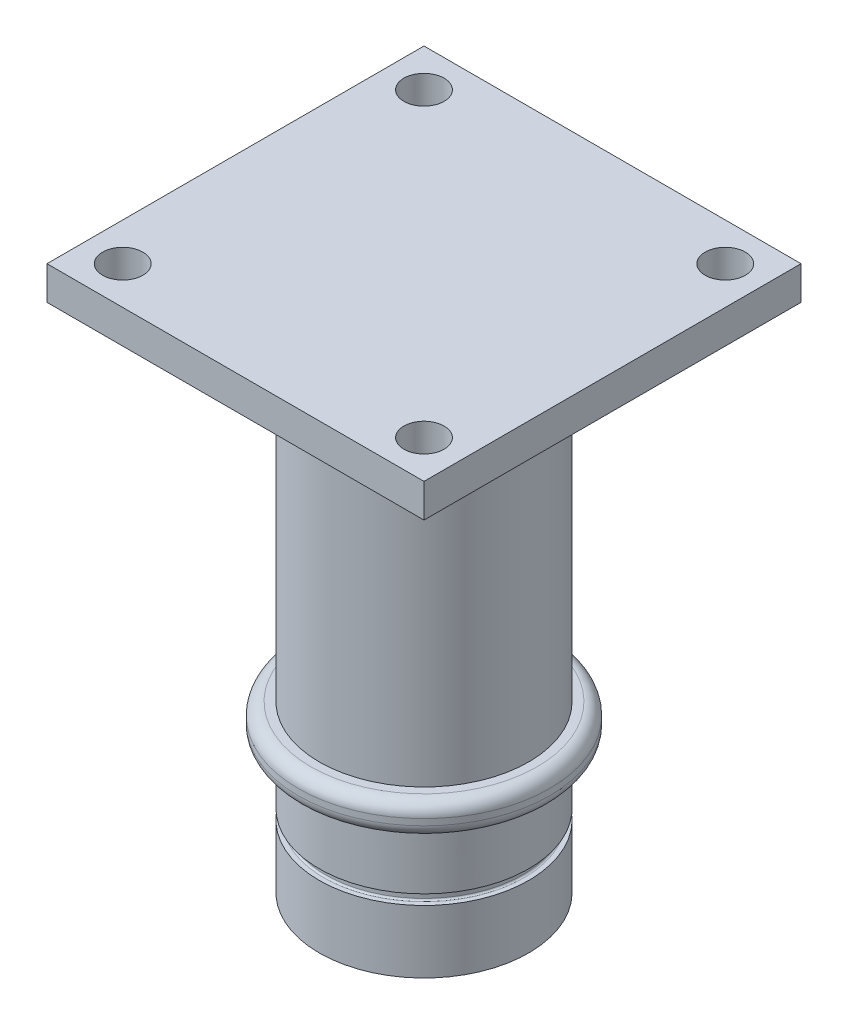
from build123d import *

# Parameters (mm, degrees)
SKETCH1_R            = 12.5
BOSS_EXTRUDE1_DEPTH  = 16
BOSS_EXTRUDE2_DEPTH  = 0.32
SKETCH4_R            = 15
BOSS_EXTRUDE3_DEPTH  = 45
SKETCH5_W            = 45
SKETCH5_H            = 45
BOSS_EXTRUDE4_DEPTH  = 4
FILLET1_R            = 1.5
M4_CLEARANCE_HOLE1_D = 4.8
SKETCH26_W           = 3.470226455
SKETCH26_H           = 40.019428233
FILLET3_R            = 1.5


with BuildPart() as part:
    # Sketch1 → Boss-Extrude1 (new body)
    with BuildSketch(Plane(origin=(0, 0, 0), x_dir=(1, 0, 0), z_dir=(0, 1, 0))):
        Circle(SKETCH1_R)
    extrude(amount=BOSS_EXTRUDE1_DEPTH)

    # Sketch3 → Boss-Extrude2 (add)
    with BuildSketch(Plane(origin=(0, 0, 0), x_dir=(-1, 0, 0), z_dir=(0, -1, 0))):
        with BuildLine():
            Line((-6.291079157, 1.543222531), (-6.919284285, 1.543222531))
            add(Edge.make_bspline(
                [(-6.919284285, 1.543222531), (-6.916571164, 1.590742925), (-6.911269887, 1.683594923), (-6.890182748, 1.818465423), (-6.861926706, 1.945903214), (-6.824215266, 2.065462506), (-6.776828375, 2.177099854), (-6.720985418, 2.281195836), (-6.655259736, 2.377202384), (-6.581050187, 2.464656501), (-6.499616645, 2.543112396), (-6.41264975, 2.612676322), (-6.318819227, 2.670078723), (-6.219839436, 2.717315584), (-6.11572723, 2.755055642), (-6.005497546, 2.780287924), (-5.890104812, 2.797375473), (-5.81110914, 2.798870702), (-5.770846785, 2.799632787)],
                knots=[0, 0, 0, 0, 0.000142716, 0.000278858, 0.000408976, 0.000534035, 0.000654361, 0.000772316, 0.000887831, 0.001002741, 0.001115793, 0.001226606, 0.001336154, 0.001444972, 0.001555191, 0.0016676, 0.00178371, 0.001904402, 0.001904402, 0.001904402, 0.001904402], degree=3))
            add(Edge.make_bspline(
                [(-5.770846785, 2.799632787), (-5.721425316, 2.798090707), (-5.624943026, 2.795080205), (-5.484746605, 2.769399626), (-5.353818476, 2.726444888), (-5.232253813, 2.666425791), (-5.121087516, 2.59017782), (-5.020338019, 2.499264594), (-4.933052148, 2.391778705), (-4.858676485, 2.272192465), (-4.796879198, 2.145567468), (-4.753574234, 2.014631969), (-4.725110347, 1.882860468), (-4.722074497, 1.794132208), (-4.720566337, 1.75005346)],
                knots=[0, 0, 0, 0, 0.000148176, 0.000289274, 0.00042585, 0.000560365, 0.000694549, 0.000829057, 0.000966049, 0.001108444, 0.001250813, 0.001387611, 0.0015214, 0.001653479, 0.001653479, 0.001653479, 0.001653479], degree=3))
            add(Edge.make_bspline(
                [(-4.720566337, 1.75005346), (-4.721153535, 1.723391518), (-4.722335419, 1.669727615), (-4.73055322, 1.588520958), (-4.742881545, 1.505802484), (-4.761469655, 1.421643116), (-4.784650551, 1.336019263), (-4.812772329, 1.248674681), (-4.846487301, 1.160104584), (-4.885232833, 1.069312129), (-4.93145635, 0.976002549), (-4.985277211, 0.878777096), (-5.048123942, 0.777722019), (-5.119237436, 0.672266726), (-5.198963072, 0.562577537), (-5.287690046, 0.448984871), (-5.384396431, 0.331088462), (-5.453031673, 0.252281329), (-5.488294702, 0.211792242)],
                knots=[0, 0, 0, 0, 7.9977e-05, 0.000160974, 0.000244663, 0.00033075, 0.000419361, 0.000510712, 0.000605902, 0.000703579, 0.00080674, 0.00091815, 0.001036838, 0.001163625, 0.001299659, 0.001443551, 0.001595983, 0.001757052, 0.001757052, 0.001757052, 0.001757052], degree=3))
            Line((-5.488294702, 0.211792242), (-5.853579157, -0.206777469))
            Line((-5.853579157, -0.206777469), (-4.675694542, -0.206777469))
            Line((-4.675694542, -0.206777469), (-4.675694542, -0.790110802))
            Line((-4.675694542, -0.790110802), (-7.009027875, -0.790110802))
            Line((-7.009027875, -0.790110802), (-7.009027875, -0.471801508))
            Line((-7.009027875, -0.471801508), (-5.972769862, 0.631063076))
            add(Edge.make_bspline(
                [(-5.972769862, 0.631063076), (-5.94276753, 0.663233978), (-5.884661909, 0.725539476), (-5.801983599, 0.817041727), (-5.727167032, 0.90387518), (-5.66176359, 0.986964434), (-5.602340985, 1.063614414), (-5.551548866, 1.136135444), (-5.508922525, 1.203871909), (-5.462645586, 1.285550256), (-5.418697706, 1.382966219), (-5.378372866, 1.495193403), (-5.353792086, 1.602456744), (-5.350399161, 1.672351843), (-5.348771465, 1.705882787)],
                knots=[0, 0, 0, 0, 0.000131967, 0.000255582, 0.000369957, 0.000475731, 0.00057277, 0.00066088, 0.000741219, 0.000812792, 0.000942363, 0.001061215, 0.001170268, 0.001270825, 0.001270825, 0.001270825, 0.001270825], degree=3))
            add(Edge.make_bspline(
                [(-5.348771465, 1.705882787), (-5.349988454, 1.738321389), (-5.352346565, 1.80117638), (-5.378260299, 1.89058727), (-5.418406753, 1.971539704), (-5.474978777, 2.041614731), (-5.543505217, 2.099200028), (-5.622693954, 2.142030354), (-5.711899369, 2.166743256), (-5.774434064, 2.169836428), (-5.806603997, 2.171427659)],
                knots=[0, 0, 0, 0, 9.7062e-05, 0.000188073, 0.000276808, 0.000366596, 0.000456186, 0.000543702, 0.000634713, 0.000731135, 0.000731135, 0.000731135, 0.000731135], degree=3))
            add(Edge.make_bspline(
                [(-5.806603997, 2.171427659), (-5.823223394, 2.170839839), (-5.855941346, 2.169682622), (-5.904034178, 2.161979337), (-5.949797963, 2.148403101), (-5.993742077, 2.130212856), (-6.035397537, 2.106101555), (-6.074659275, 2.076380536), (-6.111940963, 2.041805077), (-6.147071611, 2.00248329), (-6.179045088, 1.958600165), (-6.207443813, 1.910556483), (-6.230924831, 1.858382067), (-6.251598373, 1.8027657), (-6.267542797, 1.743110015), (-6.279152316, 1.679772045), (-6.287978258, 1.612854834), (-6.290026721, 1.566855543), (-6.291079157, 1.543222531)],
                knots=[0, 0, 0, 0, 4.9859e-05, 9.8155e-05, 0.000145635, 0.000192772, 0.000240515, 0.000289593, 0.000340201, 0.000392836, 0.000447528, 0.000502841, 0.000559939, 0.000618941, 0.00068068, 0.000744897, 0.000812032, 0.000882971, 0.000882971, 0.000882971, 0.000882971], degree=3))
        make_face()
        with BuildLine():
            Line((-3.621908484, 2.709889198), (-2.028258644, 2.709889198))
            Line((-2.028258644, 2.709889198), (-2.028258644, 2.126555864))
            Line((-2.028258644, 2.126555864), (-3.12411201, 2.126555864))
            Line((-3.12411201, 2.126555864), (-3.26083076, 1.46469689))
            add(Edge.make_bspline(
                [(-3.26083076, 1.46469689), (-3.242200873, 1.469885549), (-3.205458909, 1.480118649), (-3.150107094, 1.490381155), (-3.096463471, 1.497032985), (-3.061262853, 1.49792025), (-3.044184125, 1.498350736)],
                knots=[0, 0, 0, 0, 5.799e-05, 0.000114368, 0.000168722, 0.000219947, 0.000219947, 0.000219947, 0.000219947], degree=3))
            add(Edge.make_bspline(
                [(-3.044184125, 1.498350736), (-3.006967787, 1.497497945), (-2.933606187, 1.495816907), (-2.826287475, 1.479858368), (-2.723523468, 1.454724152), (-2.625628637, 1.418877575), (-2.53269861, 1.372222329), (-2.444620738, 1.31578256), (-2.361286921, 1.249459139), (-2.284177518, 1.173210542), (-2.213326177, 1.089487857), (-2.151724977, 0.998932913), (-2.099113708, 0.902836937), (-2.057268524, 0.800602599), (-2.024240737, 0.692871998), (-2.000374121, 0.579576097), (-1.986260599, 0.460580625), (-1.984357477, 0.379398522), (-1.98338685, 0.337994165)],
                knots=[0, 0, 0, 0, 0.000111586, 0.000219961, 0.00032471, 0.000428519, 0.000531991, 0.000636043, 0.000741817, 0.000850891, 0.00096086, 0.001070345, 0.001178899, 0.001288921, 0.00140114, 0.00151651, 0.001635827, 0.001760022, 0.001760022, 0.001760022, 0.001760022], degree=3))
            add(Edge.make_bspline(
                [(-1.98338685, 0.337994165), (-1.984572971, 0.296119774), (-1.986913536, 0.21348936), (-2.002183578, 0.091993422), (-2.029135476, -0.024372259), (-2.066156605, -0.13591919), (-2.114929572, -0.241827528), (-2.173585741, -0.343194406), (-2.243116827, -0.439267408), (-2.322840495, -0.52906167), (-2.409510579, -0.611135349), (-2.50179376, -0.683335722), (-2.599041719, -0.744091751), (-2.701256805, -0.793192894), (-2.807852575, -0.832040844), (-2.918861384, -0.860320297), (-3.03482272, -0.876536993), (-3.1135454, -0.878736441), (-3.153559125, -0.879854392)],
                knots=[0, 0, 0, 0, 0.000125626, 0.000247897, 0.00036661, 0.000483454, 0.000599853, 0.000715778, 0.000834286, 0.000954987, 0.001075509, 0.001191914, 0.001305919, 0.001418808, 0.001531482, 0.001645754, 0.001761863, 0.001881886, 0.001881886, 0.001881886, 0.001881886], degree=3))
            add(Edge.make_bspline(
                [(-3.153559125, -0.879854392), (-3.189342209, -0.878939838), (-3.259913938, -0.877136147), (-3.363862997, -0.86604971), (-3.464081433, -0.846448784), (-3.560037195, -0.81808117), (-3.6527399, -0.783167113), (-3.741117877, -0.739500487), (-3.825656778, -0.687912762), (-3.906116545, -0.629345417), (-3.98118982, -0.563371574), (-4.049708751, -0.491151836), (-4.11208816, -0.413596497), (-4.166993225, -0.329748761), (-4.214251835, -0.239732507), (-4.256161735, -0.144608598), (-4.290465408, -0.043383637), (-4.307873534, 0.02679113), (-4.316720183, 0.0624533)],
                knots=[0, 0, 0, 0, 0.000107354, 0.000211725, 0.000313201, 0.000413265, 0.000511575, 0.000610032, 0.000708511, 0.000808359, 0.000908217, 0.001007897, 0.001106663, 0.001206422, 0.001308044, 0.00141134, 0.001517986, 0.001628185, 0.001628185, 0.001628185, 0.001628185], degree=3))
            Line((-4.316720183, 0.0624533), (-3.598771465, 0.0624533))
            add(Edge.make_bspline(
                [(-3.598771465, 0.0624533), (-3.585647345, 0.037740869), (-3.560142116, -0.010284921), (-3.511625531, -0.074046374), (-3.457314294, -0.128419402), (-3.397698323, -0.17393524), (-3.332391343, -0.208034932), (-3.264054489, -0.233894561), (-3.191829275, -0.248837882), (-3.142640716, -0.250705946), (-3.117801914, -0.251649264)],
                knots=[0, 0, 0, 0, 8.3833e-05, 0.00016292, 0.000239268, 0.000313868, 0.00038695, 0.000459491, 0.000532506, 0.000606986, 0.000606986, 0.000606986, 0.000606986], degree=3))
            add(Edge.make_bspline(
                [(-3.117801914, -0.251649264), (-3.100489602, -0.250997895), (-3.066427337, -0.249716315), (-3.016241976, -0.242936434), (-2.968337843, -0.230095494), (-2.922358785, -0.212313777), (-2.878181288, -0.190137967), (-2.836438652, -0.162142453), (-2.796404632, -0.129918577), (-2.758688707, -0.092941571), (-2.72452895, -0.051720811), (-2.694574579, -0.007426293), (-2.667791241, 0.038957747), (-2.647952414, 0.089268698), (-2.631706091, 0.142004258), (-2.619741642, 0.197562227), (-2.612591534, 0.256007492), (-2.611929626, 0.295906436), (-2.611591978, 0.31625939)],
                knots=[0, 0, 0, 0, 5.1959e-05, 0.00010223, 0.000151548, 0.000200376, 0.000249918, 0.000299504, 0.000350859, 0.000403908, 0.00045768, 0.000511159, 0.000564208, 0.00061798, 0.000672982, 0.000729638, 0.000788252, 0.000849286, 0.000849286, 0.000849286, 0.000849286], degree=3))
            add(Edge.make_bspline(
                [(-2.611591978, 0.31625939), (-2.611983857, 0.336139906), (-2.61274666, 0.374837812), (-2.619056719, 0.4316602), (-2.630345293, 0.485574363), (-2.645726071, 0.536993243), (-2.665415304, 0.5856046), (-2.689476862, 0.631697791), (-2.71801354, 0.675039833), (-2.751178544, 0.714748324), (-2.786545363, 0.751170082), (-2.824540692, 0.783024261), (-2.864822211, 0.809461017), (-2.906138223, 0.832541075), (-2.950137915, 0.849338238), (-2.995831909, 0.860905825), (-3.043172153, 0.869393654), (-3.075461906, 0.869892345), (-3.091860407, 0.870145608)],
                knots=[0, 0, 0, 0, 5.9632e-05, 0.000116076, 0.000171216, 0.000224671, 0.00027688, 0.000328311, 0.000380426, 0.000432223, 0.00048329, 0.000532573, 0.000580604, 0.000627663, 0.000674276, 0.000721381, 0.000768985, 0.000818109, 0.000818109, 0.000818109, 0.000818109], degree=3))
            add(Edge.make_bspline(
                [(-3.091860407, 0.870145608), (-3.109672991, 0.869469719), (-3.14537323, 0.868115093), (-3.19841485, 0.857092866), (-3.250816936, 0.839254766), (-3.302870896, 0.814644281), (-3.354060006, 0.782436922), (-3.405735171, 0.744661381), (-3.456166712, 0.698572909), (-3.488232489, 0.66424611), (-3.504821144, 0.646487755)],
                knots=[0, 0, 0, 0, 5.34e-05, 0.000107026, 0.00016179, 0.000219183, 0.000279308, 0.000342972, 0.00041098, 0.000483874, 0.000483874, 0.000483874, 0.000483874], degree=3))
            Line((-3.504821144, 0.646487755), (-4.033466978, 0.767781826))
            Line((-4.033466978, 0.767781826), (-3.621908484, 2.709889198))
        make_face()
        with BuildLine():
            Line((-1.400053516, 1.767581505), (-0.771848388, 1.767581505))
            Line((-0.771848388, 1.767581505), (-0.771848388, 1.461892403))
            add(Edge.make_bspline(
                [(-0.771848388, 1.461892403), (-0.743906143, 1.490094158), (-0.688890159, 1.545621095), (-0.597717912, 1.617005965), (-0.502616027, 1.678048848), (-0.402432018, 1.727466904), (-0.297410934, 1.765201159), (-0.188050517, 1.792852264), (-0.073789049, 1.80916555), (0.004007568, 1.811345235), (0.043556259, 1.8124533)],
                knots=[0, 0, 0, 0, 0.000119001, 0.000234303, 0.000346528, 0.000457527, 0.000568643, 0.000680705, 0.000795425, 0.000914048, 0.000914048, 0.000914048, 0.000914048], degree=3))
            add(Edge.make_bspline(
                [(0.043556259, 1.8124533), (0.083157169, 1.811207675), (0.161110278, 1.808755703), (0.274843322, 1.786317857), (0.382587209, 1.74986394), (0.483156505, 1.69790336), (0.577278064, 1.633734745), (0.66078224, 1.554042942), (0.735946033, 1.462000309), (0.776011228, 1.392415088), (0.796561067, 1.356724133)],
                knots=[0, 0, 0, 0, 0.000118697, 0.000233651, 0.000346285, 0.000458854, 0.000572239, 0.000686814, 0.000803976, 0.00092735, 0.00092735, 0.00092735, 0.00092735], degree=3))
            add(Edge.make_bspline(
                [(0.796561067, 1.356724133), (0.823031915, 1.392512181), (0.874986762, 1.462754076), (0.967081459, 1.554462834), (1.066663304, 1.633743055), (1.175658975, 1.698377098), (1.291173926, 1.749686581), (1.412702677, 1.786182411), (1.539143407, 1.808718203), (1.625193264, 1.811197924), (1.66875658, 1.8124533)],
                knots=[0, 0, 0, 0, 0.000133377, 0.000261782, 0.000388582, 0.000514355, 0.000640857, 0.00076684, 0.000894209, 0.001024806, 0.001024806, 0.001024806, 0.001024806], degree=3))
            add(Edge.make_bspline(
                [(1.66875658, 1.8124533), (1.713752313, 1.811149786), (1.801377319, 1.808611314), (1.928358537, 1.783637189), (2.047291813, 1.745048419), (2.155548756, 1.688892314), (2.253438125, 1.622373184), (2.336851675, 1.543778056), (2.406077301, 1.45584945), (2.45115206, 1.373745586), (2.480291681, 1.301156369), (2.497886443, 1.237990149), (2.51434299, 1.167457075), (2.526165371, 1.088609083), (2.537201043, 1.002187284), (2.543607684, 0.907617117), (2.547962345, 0.805217165), (2.548424865, 0.734367196), (2.548664433, 0.697669646)],
                knots=[0, 0, 0, 0, 0.000134836, 0.000262581, 0.000386741, 0.000508716, 0.000627156, 0.000740739, 0.000851119, 0.000961576, 0.001020424, 0.001085432, 0.001158059, 0.001237592, 0.001324469, 0.00141938, 0.00152183, 0.001631915, 0.001631915, 0.001631915, 0.001631915], degree=3))
            Line((2.548664433, 0.697669646), (2.548664433, -0.790110802))
            Line((2.548664433, -0.790110802), (1.920459304, -0.790110802))
            Line((1.920459304, -0.790110802), (1.920459304, 0.494344326))
            add(Edge.make_bspline(
                [(1.920459304, 0.494344326), (1.919936443, 0.528701113), (1.918932857, 0.594645861), (1.914666226, 0.689231012), (1.905115682, 0.775011582), (1.89392122, 0.852462715), (1.87790173, 0.921173756), (1.85836887, 0.981310341), (1.835710871, 1.032959035), (1.808352021, 1.076114456), (1.777710076, 1.112458136), (1.743625333, 1.143611868), (1.706453177, 1.170192166), (1.665856587, 1.192848092), (1.620772039, 1.208170744), (1.572721513, 1.220193443), (1.521329002, 1.228380988), (1.485796231, 1.228869105), (1.467534625, 1.229119967)],
                knots=[0, 0, 0, 0, 0.000103086, 0.000197865, 0.000283886, 0.000361925, 0.000432502, 0.000495247, 0.000551416, 0.00060121, 0.000647981, 0.000693635, 0.000739359, 0.00078485, 0.000832532, 0.000881676, 0.000933435, 0.000988163, 0.000988163, 0.000988163, 0.000988163], degree=3))
            add(Edge.make_bspline(
                [(1.467534625, 1.229119967), (1.439393749, 1.228147064), (1.384172879, 1.226237935), (1.303704817, 1.207994074), (1.227983778, 1.178167313), (1.157293443, 1.137590646), (1.093154913, 1.086911156), (1.037049935, 1.026800449), (0.990715047, 0.956912101), (0.958640909, 0.892069733), (0.938598601, 0.833439204), (0.924460574, 0.783226863), (0.913440545, 0.726444133), (0.904815088, 0.663666092), (0.896539969, 0.594537848), (0.892480243, 0.519146817), (0.888325903, 0.437597735), (0.888379984, 0.381236828), (0.888408022, 0.352016601)],
                knots=[0, 0, 0, 0, 8.4321e-05, 0.000165464, 0.000246056, 0.000327715, 0.000409073, 0.000490433, 0.000573272, 0.000659817, 0.000706604, 0.000758996, 0.000816196, 0.000879952, 0.000949094, 0.001024974, 0.001106379, 0.001194022, 0.001194022, 0.001194022, 0.001194022], degree=3))
            Line((0.888408022, 0.352016601), (0.888408022, -0.790110802))
            Line((0.888408022, -0.790110802), (0.260202894, -0.790110802))
            Line((0.260202894, -0.790110802), (0.260202894, 0.436151217))
            add(Edge.make_bspline(
                [(0.260202894, 0.436151217), (0.26015015, 0.463498474), (0.260048687, 0.51610574), (0.256998914, 0.592071637), (0.252960419, 0.662215727), (0.24729892, 0.726733651), (0.240769495, 0.785545166), (0.23134603, 0.838328533), (0.221445811, 0.885374603), (0.204471751, 0.938817535), (0.180553119, 0.998041247), (0.144818332, 1.060844696), (0.101610094, 1.113427784), (0.05202049, 1.156199719), (-0.004017889, 1.188788501), (-0.065085419, 1.213030505), (-0.132348144, 1.226115594), (-0.178647308, 1.228097376), (-0.202537491, 1.229119967)],
                knots=[0, 0, 0, 0, 8.2034e-05, 0.000157807, 0.000228046, 0.000292792, 0.000352102, 0.000405471, 0.000453609, 0.000496187, 0.000573527, 0.000644838, 0.000712076, 0.000776717, 0.000840206, 0.000905696, 0.000972934, 0.001044617, 0.001044617, 0.001044617, 0.001044617], degree=3))
            add(Edge.make_bspline(
                [(-0.202537491, 1.229119967), (-0.229531342, 1.228203749), (-0.282992889, 1.226389171), (-0.360867801, 1.206899124), (-0.435323438, 1.177619628), (-0.504721853, 1.135911217), (-0.567894133, 1.084039085), (-0.623437381, 1.022218579), (-0.669528761, 0.95052303), (-0.701745271, 0.883892077), (-0.721495338, 0.823798796), (-0.736013515, 0.772282645), (-0.74662353, 0.714249432), (-0.755475948, 0.650350767), (-0.763702075, 0.580511224), (-0.767778599, 0.504423676), (-0.771928834, 0.42217246), (-0.77187585, 0.365344601), (-0.771848388, 0.3358908)],
                knots=[0, 0, 0, 0, 8.0824e-05, 0.000160072, 0.000239361, 0.000320164, 0.000401856, 0.000483779, 0.000568371, 0.000656812, 0.000704925, 0.000757993, 0.000817257, 0.000881707, 0.000951546, 0.001028125, 0.001110231, 0.001198575, 0.001198575, 0.001198575, 0.001198575], degree=3))
            Line((-0.771848388, 0.3358908), (-0.771848388, -0.790110802))
            Line((-0.771848388, -0.790110802), (-1.400053516, -0.790110802))
            Line((-1.400053516, -0.790110802), (-1.400053516, 1.767581505))
        make_face()
        with BuildLine():
            Line((3.176869561, 1.767581505), (3.805074689, 1.767581505))
            Line((3.805074689, 1.767581505), (3.805074689, 1.461892403))
            add(Edge.make_bspline(
                [(3.805074689, 1.461892403), (3.833016934, 1.490094158), (3.888032918, 1.545621095), (3.979205165, 1.617005965), (4.07430705, 1.678048848), (4.174491058, 1.727466904), (4.279512143, 1.765201159), (4.38887256, 1.792852264), (4.503134028, 1.80916555), (4.580930645, 1.811345235), (4.620479336, 1.8124533)],
                knots=[0, 0, 0, 0, 0.000119001, 0.000234303, 0.000346528, 0.000457527, 0.000568643, 0.000680705, 0.000795425, 0.000914048, 0.000914048, 0.000914048, 0.000914048], degree=3))
            add(Edge.make_bspline(
                [(4.620479336, 1.8124533), (4.660080246, 1.811207675), (4.738033355, 1.808755703), (4.851766399, 1.786317857), (4.959510286, 1.74986394), (5.060079582, 1.69790336), (5.154201141, 1.633734745), (5.237705317, 1.554042942), (5.31286911, 1.462000309), (5.352934305, 1.392415088), (5.373484144, 1.356724133)],
                knots=[0, 0, 0, 0, 0.000118697, 0.000233651, 0.000346285, 0.000458854, 0.000572239, 0.000686814, 0.000803976, 0.00092735, 0.00092735, 0.00092735, 0.00092735], degree=3))
            add(Edge.make_bspline(
                [(5.373484144, 1.356724133), (5.399954992, 1.392512181), (5.451909839, 1.462754076), (5.544004536, 1.554462834), (5.643586381, 1.633743055), (5.752582052, 1.698377098), (5.868097003, 1.749686581), (5.989625754, 1.786182411), (6.116066484, 1.808718203), (6.20211634, 1.811197924), (6.245679657, 1.8124533)],
                knots=[0, 0, 0, 0, 0.000133377, 0.000261782, 0.000388582, 0.000514355, 0.000640857, 0.00076684, 0.000894209, 0.001024806, 0.001024806, 0.001024806, 0.001024806], degree=3))
            add(Edge.make_bspline(
                [(6.245679657, 1.8124533), (6.29067539, 1.811149786), (6.378300396, 1.808611314), (6.505281614, 1.783637189), (6.62421489, 1.745048419), (6.732471833, 1.688892314), (6.830361202, 1.622373184), (6.913774752, 1.543778056), (6.983000378, 1.45584945), (7.028075137, 1.373745586), (7.057214758, 1.301156369), (7.07480952, 1.237990149), (7.091266067, 1.167457075), (7.103088448, 1.088609083), (7.11412412, 1.002187284), (7.120530761, 0.907617117), (7.124885422, 0.805217165), (7.125347942, 0.734367196), (7.125587509, 0.697669646)],
                knots=[0, 0, 0, 0, 0.000134836, 0.000262581, 0.000386741, 0.000508716, 0.000627156, 0.000740739, 0.000851119, 0.000961576, 0.001020424, 0.001085432, 0.001158059, 0.001237592, 0.001324469, 0.00141938, 0.00152183, 0.001631915, 0.001631915, 0.001631915, 0.001631915], degree=3))
            Line((7.125587509, 0.697669646), (7.125587509, -0.790110802))
            Line((7.125587509, -0.790110802), (6.497382381, -0.790110802))
            Line((6.497382381, -0.790110802), (6.497382381, 0.494344326))
            add(Edge.make_bspline(
                [(6.497382381, 0.494344326), (6.496859519, 0.528701113), (6.495855934, 0.594645861), (6.491589303, 0.689231012), (6.482038759, 0.775011582), (6.470844297, 0.852462715), (6.454824807, 0.921173756), (6.435291947, 0.981310341), (6.412633948, 1.032959035), (6.385275098, 1.076114456), (6.354633153, 1.112458136), (6.32054841, 1.143611868), (6.283376253, 1.170192166), (6.242779664, 1.192848092), (6.197695115, 1.208170744), (6.14964459, 1.220193443), (6.098252079, 1.228380988), (6.062719308, 1.228869105), (6.044457702, 1.229119967)],
                knots=[0, 0, 0, 0, 0.000103086, 0.000197865, 0.000283886, 0.000361925, 0.000432502, 0.000495247, 0.000551416, 0.00060121, 0.000647981, 0.000693635, 0.000739359, 0.00078485, 0.000832532, 0.000881676, 0.000933435, 0.000988163, 0.000988163, 0.000988163, 0.000988163], degree=3))
            add(Edge.make_bspline(
                [(6.044457702, 1.229119967), (6.016316826, 1.228147064), (5.961095956, 1.226237935), (5.880627894, 1.207994074), (5.804906855, 1.178167313), (5.73421652, 1.137590646), (5.67007799, 1.086911156), (5.613973012, 1.026800449), (5.567638124, 0.956912101), (5.535563986, 0.892069733), (5.515521678, 0.833439204), (5.501383651, 0.783226863), (5.490363622, 0.726444133), (5.481738165, 0.663666092), (5.473463046, 0.594537848), (5.46940332, 0.519146817), (5.46524898, 0.437597735), (5.465303061, 0.381236828), (5.465331099, 0.352016601)],
                knots=[0, 0, 0, 0, 8.4321e-05, 0.000165464, 0.000246056, 0.000327715, 0.000409073, 0.000490433, 0.000573272, 0.000659817, 0.000706604, 0.000758996, 0.000816196, 0.000879952, 0.000949094, 0.001024974, 0.001106379, 0.001194022, 0.001194022, 0.001194022, 0.001194022], degree=3))
            Line((5.465331099, 0.352016601), (5.465331099, -0.790110802))
            Line((5.465331099, -0.790110802), (4.837125971, -0.790110802))
            Line((4.837125971, -0.790110802), (4.837125971, 0.436151217))
            add(Edge.make_bspline(
                [(4.837125971, 0.436151217), (4.837073227, 0.463498474), (4.836971764, 0.51610574), (4.833921991, 0.592071637), (4.829883496, 0.662215727), (4.824221997, 0.726733651), (4.817692572, 0.785545166), (4.808269107, 0.838328533), (4.798368888, 0.885374603), (4.781394828, 0.938817535), (4.757476196, 0.998041247), (4.721741409, 1.060844696), (4.678533171, 1.113427784), (4.628943567, 1.156199719), (4.572905188, 1.188788501), (4.511837658, 1.213030505), (4.444574933, 1.226115594), (4.398275769, 1.228097376), (4.374385586, 1.229119967)],
                knots=[0, 0, 0, 0, 8.2034e-05, 0.000157807, 0.000228046, 0.000292792, 0.000352102, 0.000405471, 0.000453609, 0.000496187, 0.000573527, 0.000644838, 0.000712076, 0.000776717, 0.000840206, 0.000905696, 0.000972934, 0.001044617, 0.001044617, 0.001044617, 0.001044617], degree=3))
            add(Edge.make_bspline(
                [(4.374385586, 1.229119967), (4.347391735, 1.228203749), (4.293930188, 1.226389171), (4.216055276, 1.206899124), (4.141599639, 1.177619628), (4.072201223, 1.135911217), (4.009028944, 1.084039085), (3.953485696, 1.022218579), (3.907394316, 0.95052303), (3.875177806, 0.883892077), (3.855427739, 0.823798796), (3.840909562, 0.772282645), (3.830299547, 0.714249432), (3.821447129, 0.650350767), (3.813221002, 0.580511224), (3.809144477, 0.504423676), (3.804994243, 0.42217246), (3.805047227, 0.365344601), (3.805074689, 0.3358908)],
                knots=[0, 0, 0, 0, 8.0824e-05, 0.000160072, 0.000239361, 0.000320164, 0.000401856, 0.000483779, 0.000568371, 0.000656812, 0.000704925, 0.000757993, 0.000817257, 0.000881707, 0.000951546, 0.001028125, 0.001110231, 0.001198575, 0.001198575, 0.001198575, 0.001198575], degree=3))
            Line((3.805074689, 0.3358908), (3.805074689, -0.790110802))
            Line((3.805074689, -0.790110802), (3.176869561, -0.790110802))
            Line((3.176869561, -0.790110802), (3.176869561, 1.767581505))
        make_face()
    extrude(amount=BOSS_EXTRUDE2_DEPTH)

    # Sketch4 → Boss-Extrude3 (add)
    with BuildSketch(Plane(origin=(0, 16, 0), x_dir=(1, 0, 0), z_dir=(0, 1, 0))):
        Circle(SKETCH4_R)
    extrude(amount=BOSS_EXTRUDE3_DEPTH)

    # Sketch5 → Boss-Extrude4 (add)
    with BuildSketch(Plane(origin=(0, 61, 0), x_dir=(1, 0, 0), z_dir=(0, 1, 0))):
        Rectangle(SKETCH5_W, SKETCH5_H)
    extrude(amount=BOSS_EXTRUDE4_DEPTH)

    # Fillet1
    fillet1_edges = [part.edges().sort_by_distance(p)[0] for p in [
        (-15, 16, 0),
    ]]
    fillet(fillet1_edges, radius=FILLET1_R)

    # M4 Clearance Hole1 (through all)
    with Locations(Plane(origin=(0, 61, 0), x_dir=(-1, 0, 0), z_dir=(0, -1, 0))):
        with Locations((-17.978016474, 17.978016474), (17.978016474, 17.978016474), (17.978016474, -17.978016474), (-17.978016474, -17.978016474)):
            Hole(M4_CLEARANCE_HOLE1_D / 2)

    # Sketch24 → Groove for ANSI B27.7 - 3AM1-25, Basic External Retaining Ring1 (revolve, cut)
    with BuildSketch(Plane(origin=(0, 12, 0), x_dir=(0, 0, -1), z_dir=(-1, 0, 0))):
        with BuildLine():
            Line((11.95, 3.3), (15.15, 3.3))
            Line((15.15, 3.3), (15.15, 4.5))
            Line((15.15, 4.5), (11.95, 4.5))
            ThreePointArc((11.95, 4.5), (11.808578644, 4.441421356), (11.75, 4.3))
            Line((11.75, 4.3), (11.75, 3.5))
            ThreePointArc((11.75, 3.5), (11.808578644, 3.358578644), (11.95, 3.3))
        make_face()
    revolve(axis=Axis((0, 62, 0), (0, -1, 0)), mode=Mode.SUBTRACT)

    # Sketch26 → Cut-Revolve1 (revolve, cut)
    with BuildSketch(Plane(origin=(0, 0, 0), x_dir=(0, 0, -1), z_dir=(1, 0, 0))):
        with Locations((14.235113228, 39.754720601)):
            Rectangle(SKETCH26_W, SKETCH26_H)
    revolve(axis=Axis((0, 61, 0), (0, -1, 0)), mode=Mode.SUBTRACT)

    # Fillet3
    fillet3_edges = [part.edges().sort_by_distance(p)[0] for p in [
        (-15, 19.745006484, 0),
    ]]
    fillet(fillet3_edges, radius=FILLET3_R)


solid = part.part
